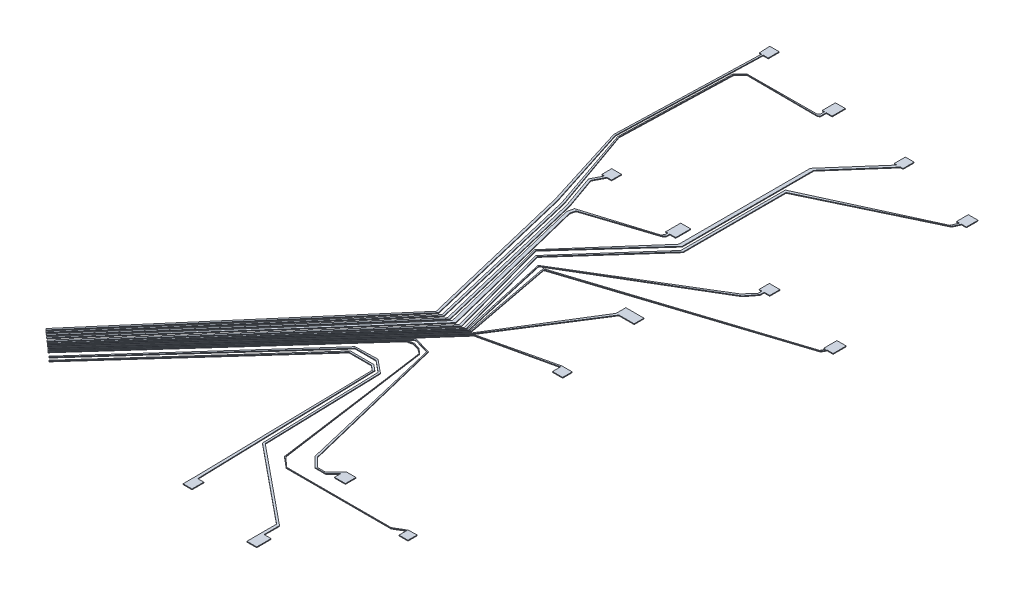
from build123d import *

# Parameters (mm, degrees)
BOSS_EXTRUDE1_DEPTH    = 0.2
BOSS_EXTRUDE1_2_DEPTH  = 0.2
BOSS_EXTRUDE1_3_DEPTH  = 0.2
BOSS_EXTRUDE1_4_DEPTH  = 0.2
BOSS_EXTRUDE1_5_DEPTH  = 0.2
BOSS_EXTRUDE1_6_DEPTH  = 0.2
BOSS_EXTRUDE1_7_DEPTH  = 0.2
BOSS_EXTRUDE1_8_DEPTH  = 0.2
BOSS_EXTRUDE1_9_DEPTH  = 0.2
BOSS_EXTRUDE1_10_DEPTH = 0.2
BOSS_EXTRUDE1_11_DEPTH = 0.2
BOSS_EXTRUDE1_12_DEPTH = 0.2
BOSS_EXTRUDE1_13_DEPTH = 0.2
BOSS_EXTRUDE1_14_DEPTH = 0.2


with BuildPart() as part:
    # Sketch3 → Boss-Extrude1 (new body)
    with BuildSketch(Plane(origin=(0, 0, 0), x_dir=(1, 0, 0), z_dir=(0, 1, 0))):
        Polygon((-38.09617257, 94.732704488), (-39.298077185, 55.25722421), (-31.95605569, 31.866543379), (-21.582832649, -11.287803205), (-71.159747359, -69.096783048), (-70.7841988, -69.418853061), (-20.931077216, -11.287803205), (-31.321797057, 31.866543379), (-38.859879467, 55.25722421), (-37.657974852, 94.732704488), (-36.253037809, 94.732704488), (-36.253037809, 97.745039753), (-38.859879467, 97.745039753), (-38.697124878, 94.732704488), align=None)
    extrude(amount=BOSS_EXTRUDE1_DEPTH)


with BuildPart() as body_2:
    # Sketch3 → Boss-Extrude1 2 (new body)
    with BuildSketch(Plane(origin=(0, 0, 0), x_dir=(1, 0, 0), z_dir=(0, 1, 0))):
        Polygon((-15.710789356, 89.682313502), (-15.710789356, 88.590976213), (-16.195405168, 88.106360402), (-35.415461555, 88.004449148), (-37.285832787, 86.134077916), (-38.22593618, 55.25722421), (-30.207857052, 31.866543379), (-19.99284687, -11.287803205), (-70.536105571, -69.692729917), (-70.222147428, -69.964427333), (-19.443763481, -11.287803205), (-29.699983187, 32.040637193), (-37.956150878, 55.349703771), (-37.021557539, 86.045584696), (-35.261413127, 87.85040072), (-15.710789356, 87.753107551), (-15.235743535, 88.106360402), (-15.235743535, 89.682313502), (-13.618834585, 89.682313502), (-13.618834585, 93.311564712), (-16.325034027, 93.311564712), (-16.325034027, 89.682313502), align=None)
    extrude(amount=BOSS_EXTRUDE1_2_DEPTH)


with BuildPart() as body_3:
    # Sketch3 → Boss-Extrude1 3 (new body)
    with BuildSketch(Plane(origin=(0, 0, 0), x_dir=(1, 0, 0), z_dir=(0, 1, 0))):
        Polygon((-30.671110206, 44.101407032), (-32.168656651, 41.171424857), (-28.945570876, 32.040637193), (-18.495165346, -11.287803205), (-69.887247706, -70.301068178), (-69.524732688, -70.616766719), (-17.857722218, -11.287803205), (-28.343171049, 32.185930272), (-31.514969677, 41.171424857), (-30.017423232, 44.101407032), (-28.723442469, 44.101407032), (-28.723442469, 46.839715942), (-31.419883428, 46.839715942), (-31.419883428, 44.101407032), align=None)
    extrude(amount=BOSS_EXTRUDE1_3_DEPTH)


with BuildPart() as body_4:
    # Sketch3 → Boss-Extrude1 4 (new body)
    with BuildSketch(Plane(origin=(0, 0, 0), x_dir=(1, 0, 0), z_dir=(0, 1, 0))):
        Polygon((-8.366546687, 39.237498678), (-8.366546687, 38.426077477), (-8.96136844, 37.743046705), (-27.011807754, 32.185930272), (-27.409992513, 30.439639104), (-17.14838239, -11.287803205), (-69.121329892, -70.968072645), (-68.809127604, -71.239956022), (-16.195405168, -11.287803205), (-26.610066728, 30.439639104), (-26.284707735, 31.866543379), (-8.366546687, 37.743046705), (-7.827287572, 38.357520332), (-7.827287572, 39.237498678), (-6.205630296, 39.237498678), (-6.205630296, 43.352720162), (-8.96136844, 43.352720162), (-8.96136844, 39.237498678), align=None)
    extrude(amount=BOSS_EXTRUDE1_4_DEPTH)


with BuildPart() as body_5:
    # Sketch3 → Boss-Extrude1 5 (new body)
    with BuildSketch(Plane(origin=(0, 0, 0), x_dir=(1, 0, 0), z_dir=(0, 1, 0))):
        Polygon((6.978633508, 86.953502825), (-4.183625701, 74.234359628), (-4.183625701, 38.050283518), (-22.710355774, 16.939491483), (-15.235743535, -11.287803205), (-68.266998989, -71.7157255), (-67.90282203, -72.035325456), (-14.591087185, -11.287803205), (-22.390686956, 16.939491483), (-3.220518167, 38.050283518), (-3.220518167, 74.234359628), (7.941741041, 86.953502825), (8.634639963, 86.953502825), (8.634639963, 90.004894331), (6.213560383, 90.004894331), (6.213560383, 86.953502825), align=None)
    extrude(amount=BOSS_EXTRUDE1_5_DEPTH)


with BuildPart() as body_6:
    # Sketch3 → Boss-Extrude1 6 (new body)
    with BuildSketch(Plane(origin=(0, 0, 0), x_dir=(1, 0, 0), z_dir=(0, 1, 0))):
        Polygon((29.413066093, 81.733737374), (28.612758597, 81.733737374), (28.612758597, 84.934967357), (31.275850781, 84.934967357), (31.275850781, 81.733737374), (29.944304689, 81.733737374), (29.103817844, 79.860739051), (-1.762398512, 65.158351501), (-1.762398512, 36.853852004), (-20.702614497, 15.649924308), (-13.356804699, -11.287803205), (-67.461291016, -72.416773375), (-67.739820236, -72.170250649), (-13.853528098, -11.287803205), (-21.199337895, 15.649924308), (-2.432006911, 36.853852004), (-2.432006911, 65.629855213), (28.612758597, 79.860739051), align=None)
    extrude(amount=BOSS_EXTRUDE1_6_DEPTH)


with BuildPart() as body_7:
    # Sketch3 → Boss-Extrude1 7 (new body)
    with BuildSketch(Plane(origin=(0, 0, 0), x_dir=(1, 0, 0), z_dir=(0, 1, 0))):
        Polygon((18.429341209, 38.357520332), (18.429341209, 37.258871021), (16.095065111, 34.645605066), (-18.495165346, 13.678140386), (-13.052180604, -11.287803205), (-67.323613997, -72.538629581), (-67.181341411, -72.664690528), (-12.652787597, -11.287803205), (-18.265205265, 13.607009924), (16.866370052, 34.472387369), (19.012319832, 37.258871021), (19.012319832, 38.357520332), (20.537073623, 38.357520332), (20.537073623, 41.171424857), (17.628746948, 41.171424857), (17.628746948, 38.357520332), align=None)
    extrude(amount=BOSS_EXTRUDE1_7_DEPTH)


with BuildPart() as body_8:
    # Sketch3 → Boss-Extrude1 8 (new body)
    with BuildSketch(Plane(origin=(0, 0, 0), x_dir=(1, 0, 0), z_dir=(0, 1, 0))):
        Polygon((41.032711833, 33.247707144), (40.542600001, 32.155508444), (-17.029709598, 13.607009924), (-12.255437837, -11.287803205), (-66.959270591, -72.861983047), (-66.747098646, -73.05048119), (-11.93710822, -11.356811153), (-16.681779897, 13.383656227), (40.798586947, 32.040637193), (41.486728708, 33.247707144), (43.095501761, 33.247707144), (43.095501761, 36.853852004), (40.542600001, 36.853852004), (40.542600001, 33.247707144), align=None)
    extrude(amount=BOSS_EXTRUDE1_8_DEPTH)


with BuildPart() as body_9:
    # Sketch3 → Boss-Extrude1 9 (new body)
    with BuildSketch(Plane(origin=(0, 0, 0), x_dir=(1, 0, 0), z_dir=(0, 1, 0))):
        Polygon((3.656088835, 15.649924308), (3.656088835, 12.952785487), (-11.399245046, -11.356811153), (-66.446497694, -73.317541576), (-66.199405257, -73.537063839), (-11.152152609, -11.576333417), (4.448075995, 12.952785487), (8.634639963, 12.952785487), (8.634639963, 15.649924308), align=None)
    extrude(amount=BOSS_EXTRUDE1_9_DEPTH)


with BuildPart() as body_10:
    # Sketch3 → Boss-Extrude1 10 (new body)
    with BuildSketch(Plane(origin=(0, 0, 0), x_dir=(1, 0, 0), z_dir=(0, 1, 0))):
        Polygon((8.78223596, -7.029028436), (11.569412391, -7.029028436), (11.569412391, -9.65604264), (8.78223596, -9.65604264), (8.78223596, -7.437067693), (-10.671795262, -11.821346423), (-65.806060668, -73.889403254), (-66.007861825, -73.710145853), (-10.873596419, -11.642089023), align=None)
    extrude(amount=BOSS_EXTRUDE1_10_DEPTH)


with BuildPart() as body_11:
    # Sketch3 → Boss-Extrude1 11 (new body)
    with BuildSketch(Plane(origin=(0, 0, 0), x_dir=(1, 0, 0), z_dir=(0, 1, 0))):
        Polygon((4.448075995, -61.939512694), (1.53881982, -64.848768869), (-0.764685282, -64.848768869), (-3.178419236, -62.435034915), (-13.052180604, -22.01117916), (-17.857722218, -20.606217638), (-65.693330956, -73.993570474), (-65.579433877, -74.09562341), (-17.939422268, -21.194188748), (-17.493431237, -20.932626046), (-13.461974987, -22.111273817), (-13.215037418, -22.333651692), (-3.701663336, -62.562840323), (-1.090210036, -65.174293623), (1.864344574, -65.174293623), (3.978798265, -63.059839932), (3.978798265, -64.848768869), (6.978633508, -64.848768869), (6.978633508, -61.939512694), align=None)
    extrude(amount=BOSS_EXTRUDE1_11_DEPTH)


with BuildPart() as body_12:
    # Sketch3 → Boss-Extrude1 12 (new body)
    with BuildSketch(Plane(origin=(0, 0, 0), x_dir=(1, 0, 0), z_dir=(0, 1, 0))):
        Polygon((26.755526351, -67.296694765), (23.769823662, -69.047735501), (-4.963651914, -69.047735501), (-7.711764881, -66.572941869), (-13.758914703, -23.709269605), (-15.139023948, -22.466422018), (-17.029709598, -21.913655899), (-18.726630303, -22.314942676), (-65.456527514, -74.205748756), (-65.265693413, -74.377603052), (-18.675973558, -22.529154766), (-17.029709598, -22.139847265), (-15.199946471, -22.674801906), (-13.828839955, -23.751626833), (-7.884928437, -66.597371553), (-7.860219421, -66.775482586), (-4.963651914, -69.184816938), (23.910769431, -69.184816938), (26.644723705, -67.581420416), (26.644723705, -69.753075382), (29.103817844, -69.753075382), (29.103817844, -67.229978295), align=None)
    extrude(amount=BOSS_EXTRUDE1_12_DEPTH)


with BuildPart() as body_13:
    # Sketch3 → Boss-Extrude1 13 (new body)
    with BuildSketch(Plane(origin=(0, 0, 0), x_dir=(1, 0, 0), z_dir=(0, 1, 0))):
        Polygon((-14.514393213, -83.987043539), (-15.939292725, -33.833319681), (-17.464946885, -32.564296615), (-23.934551101, -32.564296615), (-63.186091173, -76.246281652), (-62.98356244, -76.428268911), (-23.837316433, -33.026510699), (-17.672699496, -33.026510699), (-16.305447867, -34.163776207), (-15.311170919, -83.501144796), (-15.311170919, -87.236360633), (-12.837427908, -87.236360633), (-12.837427908, -83.987043539), align=None)
    extrude(amount=BOSS_EXTRUDE1_13_DEPTH)


with BuildPart() as body_14:
    # Sketch3 → Boss-Extrude1 14 (new body)
    with BuildSketch(Plane(origin=(0, 0, 0), x_dir=(1, 0, 0), z_dir=(0, 1, 0))):
        Polygon((7.183981688, -88.18611112), (7.183981688, -83.987043539), (-14.086645795, -66.597371553), (-15.017493556, -33.833319681), (-18.172050221, -31.254331086), (-23.934551101, -31.254331086), (-63.919002644, -75.514554335), (-64.165126279, -75.292207546), (-24.321229897, -30.905007507), (-18.172050221, -30.730305363), (-14.514393213, -33.720600579), (-13.58760679, -66.341701176), (7.941741041, -83.942888408), (7.941741041, -88.18611112), (9.876517983, -88.18611112), (9.876517983, -92.163519394), (7.183981688, -92.163519394), align=None)
    extrude(amount=BOSS_EXTRUDE1_14_DEPTH)


solid = Compound([part.part, body_2.part, body_3.part, body_4.part, body_5.part, body_6.part, body_7.part, body_8.part, body_9.part, body_10.part, body_11.part, body_12.part, body_13.part, body_14.part])
